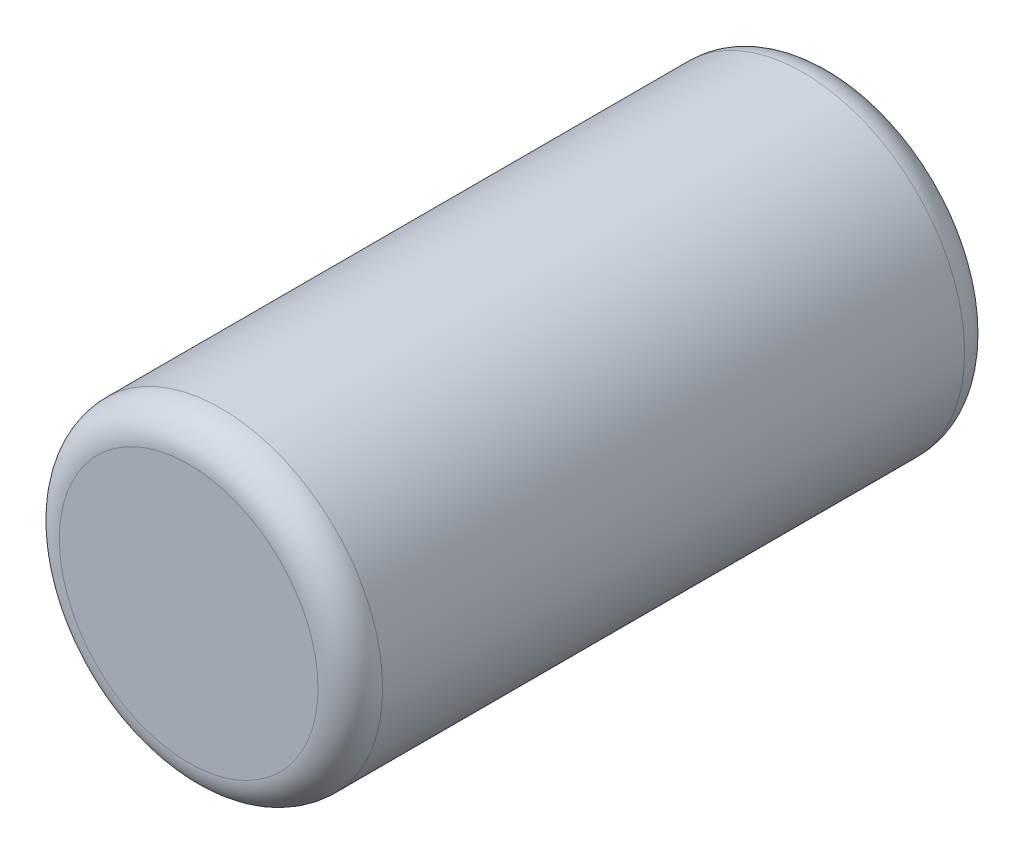
from build123d import *

# Parameters (mm, degrees)
SKETCH1_R           = 1.27
BOSS_EXTRUDE1_DEPTH = 2.54
FILLET2_R           = 0.254


with BuildPart() as part:
    # Sketch1 → Boss-Extrude1 (new body, symmetric)
    with BuildSketch(Plane.XY):
        Circle(SKETCH1_R)
    extrude(amount=BOSS_EXTRUDE1_DEPTH, both=True)

    # Fillet2
    fillet2_edges = [part.edges().sort_by_distance(p)[0] for p in [
        (-1.27, 0, -2.54),
        (-1.27, 0, 2.54),
    ]]
    fillet(fillet2_edges, radius=FILLET2_R)


solid = part.part
